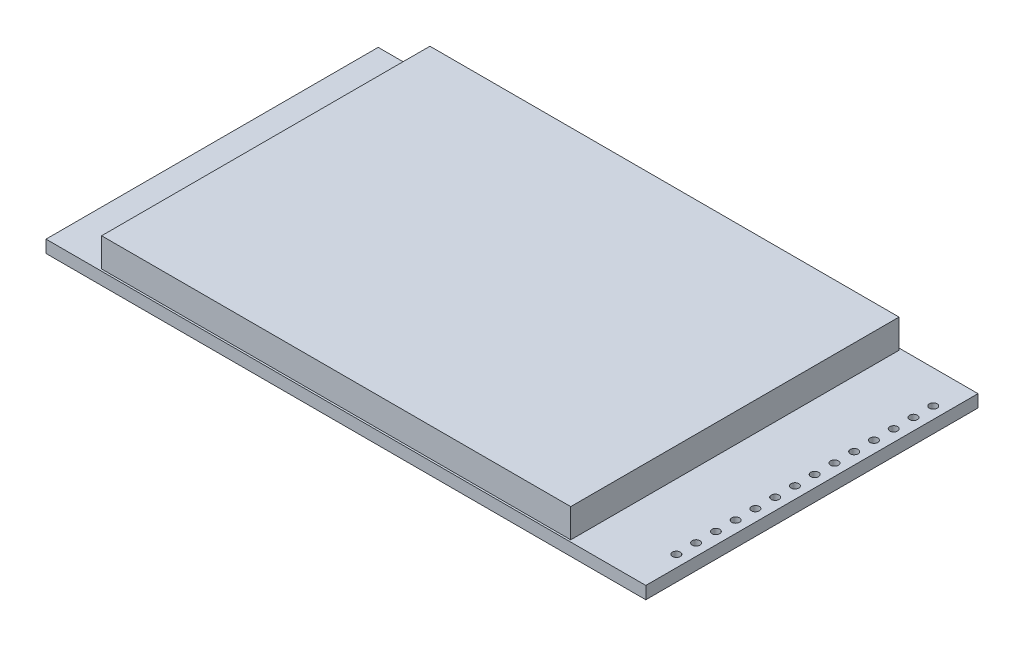
from build123d import *

# Parameters (mm, degrees)
CROQUIS1_W              = 77.1
CROQUIS1_H              = 42.7
SALIENTE_EXTRUIR1_DEPTH = 1.6
CROQUIS2_W              = 60.3
CROQUIS2_H              = 42.2
SALIENTE_EXTRUIR2_DEPTH = 3.7
CORTAR_EXTRUIR1_REACH   = 3.6
CROQUIS3_R              = 0.5


with BuildPart() as part:
    # Croquis1 → Saliente-Extruir1 (new body)
    with BuildSketch(Plane(origin=(0, 0, 0), x_dir=(1, 0, 0), z_dir=(0, 1, 0))):
        Rectangle(CROQUIS1_W, CROQUIS1_H)
    extrude(amount=SALIENTE_EXTRUIR1_DEPTH)

    # Croquis2 → Saliente-Extruir2 (add)
    with BuildSketch(Plane(origin=(0, 1.6, 0), x_dir=(1, 0, 0), z_dir=(0, 1, 0))):
        with Locations((-1.5, 0)):
            Rectangle(CROQUIS2_W, CROQUIS2_H)
    extrude(amount=SALIENTE_EXTRUIR2_DEPTH)

    # Croquis3 → Cortar-Extruir1 (cut, up to next)
    with BuildSketch(Plane(origin=(0, 1.6, 0), x_dir=(1, 0, 0), z_dir=(0, 1, 0)), mode=Mode.PRIVATE) as cortar_extruir1_sk1:
        with Locations((37.05, -15.923235508)):
            Circle(CROQUIS3_R)
    cortar_extruir1_tool1 = extrude(cortar_extruir1_sk1.sketch, amount=-CORTAR_EXTRUIR1_REACH, mode=Mode.PRIVATE) & part.part
    add(cortar_extruir1_tool1.solids().sort_by_distance((37.05, 1.6, 15.923236))[0], mode=Mode.SUBTRACT)
    # Croquis3 → Cortar-Extruir1 (cut, up to next)
    with BuildSketch(Plane(origin=(0, 1.6, 0), x_dir=(1, 0, 0), z_dir=(0, 1, 0)), mode=Mode.PRIVATE) as cortar_extruir1_sk2:
        with Locations((37.05, -13.383235508)):
            Circle(CROQUIS3_R)
    cortar_extruir1_tool2 = extrude(cortar_extruir1_sk2.sketch, amount=-CORTAR_EXTRUIR1_REACH, mode=Mode.PRIVATE) & part.part
    add(cortar_extruir1_tool2.solids().sort_by_distance((37.05, 1.6, 13.383236))[0], mode=Mode.SUBTRACT)
    # Croquis3 → Cortar-Extruir1 (cut, up to next)
    with BuildSketch(Plane(origin=(0, 1.6, 0), x_dir=(1, 0, 0), z_dir=(0, 1, 0)), mode=Mode.PRIVATE) as cortar_extruir1_sk3:
        with Locations((37.05, -10.843235508)):
            Circle(CROQUIS3_R)
    cortar_extruir1_tool3 = extrude(cortar_extruir1_sk3.sketch, amount=-CORTAR_EXTRUIR1_REACH, mode=Mode.PRIVATE) & part.part
    add(cortar_extruir1_tool3.solids().sort_by_distance((37.05, 1.6, 10.843236))[0], mode=Mode.SUBTRACT)
    # Croquis3 → Cortar-Extruir1 (cut, up to next)
    with BuildSketch(Plane(origin=(0, 1.6, 0), x_dir=(1, 0, 0), z_dir=(0, 1, 0)), mode=Mode.PRIVATE) as cortar_extruir1_sk4:
        with Locations((37.05, -8.303235508)):
            Circle(CROQUIS3_R)
    cortar_extruir1_tool4 = extrude(cortar_extruir1_sk4.sketch, amount=-CORTAR_EXTRUIR1_REACH, mode=Mode.PRIVATE) & part.part
    add(cortar_extruir1_tool4.solids().sort_by_distance((37.05, 1.6, 8.303236))[0], mode=Mode.SUBTRACT)
    # Croquis3 → Cortar-Extruir1 (cut, up to next)
    with BuildSketch(Plane(origin=(0, 1.6, 0), x_dir=(1, 0, 0), z_dir=(0, 1, 0)), mode=Mode.PRIVATE) as cortar_extruir1_sk5:
        with Locations((37.05, -5.763235508)):
            Circle(CROQUIS3_R)
    cortar_extruir1_tool5 = extrude(cortar_extruir1_sk5.sketch, amount=-CORTAR_EXTRUIR1_REACH, mode=Mode.PRIVATE) & part.part
    add(cortar_extruir1_tool5.solids().sort_by_distance((37.05, 1.6, 5.763236))[0], mode=Mode.SUBTRACT)
    # Croquis3 → Cortar-Extruir1 (cut, up to next)
    with BuildSketch(Plane(origin=(0, 1.6, 0), x_dir=(1, 0, 0), z_dir=(0, 1, 0)), mode=Mode.PRIVATE) as cortar_extruir1_sk6:
        with Locations((37.05, -3.223235508)):
            Circle(CROQUIS3_R)
    cortar_extruir1_tool6 = extrude(cortar_extruir1_sk6.sketch, amount=-CORTAR_EXTRUIR1_REACH, mode=Mode.PRIVATE) & part.part
    add(cortar_extruir1_tool6.solids().sort_by_distance((37.05, 1.6, 3.223236))[0], mode=Mode.SUBTRACT)
    # Croquis3 → Cortar-Extruir1 (cut, up to next)
    with BuildSketch(Plane(origin=(0, 1.6, 0), x_dir=(1, 0, 0), z_dir=(0, 1, 0)), mode=Mode.PRIVATE) as cortar_extruir1_sk7:
        with Locations((37.05, -0.683235508)):
            Circle(CROQUIS3_R)
    cortar_extruir1_tool7 = extrude(cortar_extruir1_sk7.sketch, amount=-CORTAR_EXTRUIR1_REACH, mode=Mode.PRIVATE) & part.part
    add(cortar_extruir1_tool7.solids().sort_by_distance((37.05, 1.6, 0.683236))[0], mode=Mode.SUBTRACT)
    # Croquis3 → Cortar-Extruir1 (cut, up to next)
    with BuildSketch(Plane(origin=(0, 1.6, 0), x_dir=(1, 0, 0), z_dir=(0, 1, 0)), mode=Mode.PRIVATE) as cortar_extruir1_sk8:
        with Locations((37.05, 1.856764492)):
            Circle(CROQUIS3_R)
    cortar_extruir1_tool8 = extrude(cortar_extruir1_sk8.sketch, amount=-CORTAR_EXTRUIR1_REACH, mode=Mode.PRIVATE) & part.part
    add(cortar_extruir1_tool8.solids().sort_by_distance((37.05, 1.6, -1.856764))[0], mode=Mode.SUBTRACT)
    # Croquis3 → Cortar-Extruir1 (cut, up to next)
    with BuildSketch(Plane(origin=(0, 1.6, 0), x_dir=(1, 0, 0), z_dir=(0, 1, 0)), mode=Mode.PRIVATE) as cortar_extruir1_sk9:
        with Locations((37.05, 4.396764492)):
            Circle(CROQUIS3_R)
    cortar_extruir1_tool9 = extrude(cortar_extruir1_sk9.sketch, amount=-CORTAR_EXTRUIR1_REACH, mode=Mode.PRIVATE) & part.part
    add(cortar_extruir1_tool9.solids().sort_by_distance((37.05, 1.6, -4.396764))[0], mode=Mode.SUBTRACT)
    # Croquis3 → Cortar-Extruir1 (cut, up to next)
    with BuildSketch(Plane(origin=(0, 1.6, 0), x_dir=(1, 0, 0), z_dir=(0, 1, 0)), mode=Mode.PRIVATE) as cortar_extruir1_sk10:
        with Locations((37.05, 6.936764492)):
            Circle(CROQUIS3_R)
    cortar_extruir1_tool10 = extrude(cortar_extruir1_sk10.sketch, amount=-CORTAR_EXTRUIR1_REACH, mode=Mode.PRIVATE) & part.part
    add(cortar_extruir1_tool10.solids().sort_by_distance((37.05, 1.6, -6.936764))[0], mode=Mode.SUBTRACT)
    # Croquis3 → Cortar-Extruir1 (cut, up to next)
    with BuildSketch(Plane(origin=(0, 1.6, 0), x_dir=(1, 0, 0), z_dir=(0, 1, 0)), mode=Mode.PRIVATE) as cortar_extruir1_sk11:
        with Locations((37.05, 9.476764492)):
            Circle(CROQUIS3_R)
    cortar_extruir1_tool11 = extrude(cortar_extruir1_sk11.sketch, amount=-CORTAR_EXTRUIR1_REACH, mode=Mode.PRIVATE) & part.part
    add(cortar_extruir1_tool11.solids().sort_by_distance((37.05, 1.6, -9.476764))[0], mode=Mode.SUBTRACT)
    # Croquis3 → Cortar-Extruir1 (cut, up to next)
    with BuildSketch(Plane(origin=(0, 1.6, 0), x_dir=(1, 0, 0), z_dir=(0, 1, 0)), mode=Mode.PRIVATE) as cortar_extruir1_sk12:
        with Locations((37.05, 12.016764492)):
            Circle(CROQUIS3_R)
    cortar_extruir1_tool12 = extrude(cortar_extruir1_sk12.sketch, amount=-CORTAR_EXTRUIR1_REACH, mode=Mode.PRIVATE) & part.part
    add(cortar_extruir1_tool12.solids().sort_by_distance((37.05, 1.6, -12.016764))[0], mode=Mode.SUBTRACT)
    # Croquis3 → Cortar-Extruir1 (cut, up to next)
    with BuildSketch(Plane(origin=(0, 1.6, 0), x_dir=(1, 0, 0), z_dir=(0, 1, 0)), mode=Mode.PRIVATE) as cortar_extruir1_sk13:
        with Locations((37.05, 14.556764492)):
            Circle(CROQUIS3_R)
    cortar_extruir1_tool13 = extrude(cortar_extruir1_sk13.sketch, amount=-CORTAR_EXTRUIR1_REACH, mode=Mode.PRIVATE) & part.part
    add(cortar_extruir1_tool13.solids().sort_by_distance((37.05, 1.6, -14.556764))[0], mode=Mode.SUBTRACT)
    # Croquis3 → Cortar-Extruir1 (cut, up to next)
    with BuildSketch(Plane(origin=(0, 1.6, 0), x_dir=(1, 0, 0), z_dir=(0, 1, 0)), mode=Mode.PRIVATE) as cortar_extruir1_sk14:
        with Locations((37.05, 17.096764492)):
            Circle(CROQUIS3_R)
    cortar_extruir1_tool14 = extrude(cortar_extruir1_sk14.sketch, amount=-CORTAR_EXTRUIR1_REACH, mode=Mode.PRIVATE) & part.part
    add(cortar_extruir1_tool14.solids().sort_by_distance((37.05, 1.6, -17.096764))[0], mode=Mode.SUBTRACT)


solid = part.part
